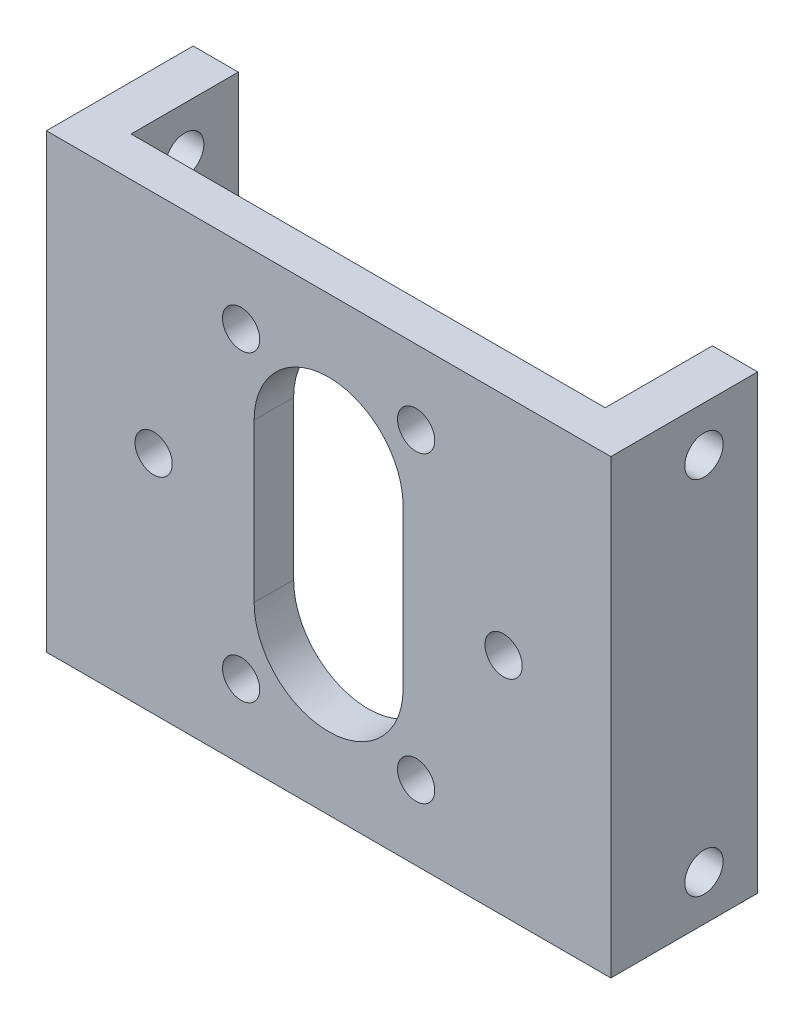
from build123d import *

# Parameters (mm, degrees)
SKETCH_1_W               = 50
SKETCH_1_H               = 40
EXTRUDE_1_DEPTH          = 5
SKETCH_2_W               = 6
SKETCH_2_H               = 40
EXTRUDE_2_DEPTH          = 8
SKETCH_3_R               = 1.65
CUT_EXTRUDE_1_DEPTH      = 6
SKETCH_4_W               = 38
SKETCH_4_H               = 40
CUT_EXTRUDE_2_DEPTH      = 1.5
SKETCH_6_R               = 1.7
CUT_EXTRUDE_3_DEPTH      = 45
CUT_EXTRUDE_3_DEPTH_BACK = 7
SKETCH_7_W               = 42
SKETCH_7_H               = 9.5
CUT_EXTRUDE_4_DEPTH      = 41


with BuildPart() as part:
    # 草图1 → 凸台-拉伸1 (new body)
    with BuildSketch(Plane.XY):
        Rectangle(SKETCH_1_W, SKETCH_1_H)
    extrude(amount=EXTRUDE_1_DEPTH)

    # 草图2 → 凸台-拉伸2 (add)
    with BuildSketch(Plane(origin=(0, 0, 0), x_dir=(-1, 0, 0), z_dir=(0, 0, -1))):
        with Locations((-22, 0)):
            Rectangle(SKETCH_2_W, SKETCH_2_H)
        with Locations((22, 0)):
            Rectangle(SKETCH_2_W, SKETCH_2_H)
    extrude(amount=EXTRUDE_2_DEPTH)

    # 草图3 → 切除-拉伸1 (cut, through all)
    with BuildSketch(Plane(origin=(0, 0, 0), x_dir=(-1, 0, 0), z_dir=(0, 0, -1))):
        with Locations((-15.5, 0)):
            Circle(SKETCH_3_R)
        with Locations((-7.75, 13.423393759)):
            Circle(SKETCH_3_R)
        with Locations((7.75, 13.423393759)):
            Circle(SKETCH_3_R)
        with Locations((15.5, 0)):
            Circle(SKETCH_3_R)
        with Locations((7.75, -13.423393759)):
            Circle(SKETCH_3_R)
        with Locations((-7.75, -13.423393759)):
            Circle(SKETCH_3_R)
        with BuildLine():
            Line((-6.6, 7), (-6.6, -7))
            ThreePointArc((-6.6, -7), (0, -13.6), (6.6, -7))
            Line((6.6, -7), (6.6, 7))
            ThreePointArc((6.6, 7), (0, 13.6), (-6.6, 7))
        make_face()
    extrude(amount=-CUT_EXTRUDE_1_DEPTH, mode=Mode.SUBTRACT)

    # 草图4 → 切除-拉伸2 (cut)
    with BuildSketch(Plane(origin=(0, 0, 0), x_dir=(-1, 0, 0), z_dir=(0, 0, -1))):
        Rectangle(SKETCH_4_W, SKETCH_4_H)
    extrude(amount=-CUT_EXTRUDE_2_DEPTH, mode=Mode.SUBTRACT)

    # 草图6 → 切除-拉伸3 (cut, two sides)
    with BuildSketch(Plane(origin=(-19, 0, 0), x_dir=(0, 0, -1), z_dir=(1, 0, 0))) as cut_extrude_3_sk:
        with Locations((3.25, 16)):
            Circle(SKETCH_6_R)
        with Locations((3.25, -16)):
            Circle(SKETCH_6_R)
    extrude(amount=CUT_EXTRUDE_3_DEPTH, mode=Mode.SUBTRACT)
    extrude(cut_extrude_3_sk.sketch, amount=-CUT_EXTRUDE_3_DEPTH_BACK, mode=Mode.SUBTRACT)

    # 草图7 → 切除-拉伸4 (cut, through all)
    with BuildSketch(Plane.XZ.offset(20)):
        with Locations((0, -3.25)):
            Rectangle(SKETCH_7_W, SKETCH_7_H)
    extrude(amount=-CUT_EXTRUDE_4_DEPTH, mode=Mode.SUBTRACT)


solid = part.part
